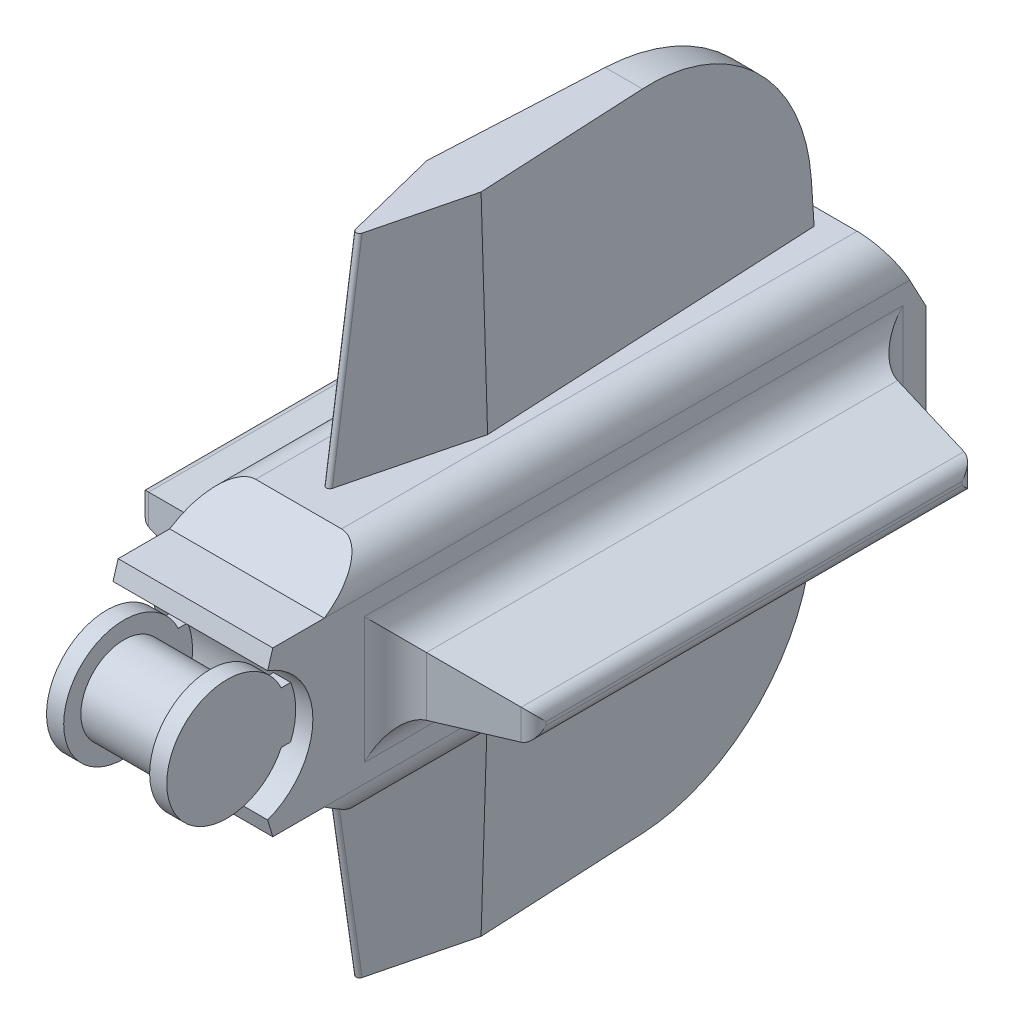
from build123d import *

# Parameters (mm, degrees)
SKETCH1_R                = 3.175
BOSS_EXTRUDE1_DEPTH      = 3.175
SKETCH2_R                = 4.445
BOSS_EXTRUDE2_DEPTH      = 1.27
SKETCH3_W                = 6.35
SKETCH3_H                = 3.81
BOSS_EXTRUDE3_DEPTH      = 1.27
BOSS_EXTRUDE4_DEPTH      = 8.89
BOSS_EXTRUDE4_DEPTH_BACK = 2.54
SKETCH5_R                = 3.175
CUT_EXTRUDE1_DEPTH       = 12.7
FILLET1_R                = 2.54
SKETCH6_W                = 35.56
SKETCH6_H                = 5.08
BOSS_EXTRUDE5_DEPTH      = 8.89
BOSS_EXTRUDE5_TAPER      = 10
FILLET2_R                = 1.016
FILLET3_R                = 2.54
BOSS_EXTRUDE6_DEPTH      = 15.24
BOSS_EXTRUDE6_TAPER      = 2
FILLET4_R                = 0.254
FILLET5_R                = 12.7


with BuildPart() as part:
    # Sketch1 → Boss-Extrude1 (new body, symmetric)
    with BuildSketch(Plane(origin=(0, 0, 0), x_dir=(0, 0, -1), z_dir=(1, 0, 0))):
        Circle(SKETCH1_R)
    extrude(amount=BOSS_EXTRUDE1_DEPTH, both=True)

    # Sketch2 → Boss-Extrude2 (add)
    with BuildSketch(Plane(origin=(3.175, 0, 0), x_dir=(0, 0, -1), z_dir=(1, 0, 0))):
        Circle(SKETCH2_R)
    boss_extrude2 = extrude(amount=BOSS_EXTRUDE2_DEPTH)

    # Mirror1: Boss-Extrude2 across plane
    add(boss_extrude2.mirror(Plane(origin=(0, 0, 0), x_dir=(0, 0, 1), z_dir=(1, 0, 0))))

    # Sketch3 → Boss-Extrude3 (add)
    with BuildSketch(Plane(origin=(4.445, 0, 0), x_dir=(0, 0, -1), z_dir=(1, 0, 0))):
        with Locations((3.175, 0)):
            Rectangle(SKETCH3_W, SKETCH3_H)
    boss_extrude3 = extrude(amount=-BOSS_EXTRUDE3_DEPTH)

    # Mirror2: Boss-Extrude3 across plane
    add(boss_extrude3.mirror(Plane(origin=(0, 0, 0), x_dir=(0, 0, 1), z_dir=(1, 0, 0))))

    # Sketch4 → Boss-Extrude4 (add, two sides)
    with BuildSketch(Plane(origin=(-3.175, 0, 0), x_dir=(0, 0, -1), z_dir=(1, 0, 0))) as boss_extrude4_sk:
        with BuildLine():
            Line((1.737462328, 4.773638514), (2.118462328, 6.043638514))
            Line((2.118462328, 6.043638514), (5.928462328, 6.043638514))
            Line((5.928462328, 6.043638514), (9.738462328, 8.583638514))
            Line((9.738462328, 8.583638514), (47.838462328, 8.583638514))
            Line((47.838462328, 8.583638514), (50.378462328, 3.81))
            Line((50.378462328, 3.81), (50.378462328, -3.81))
            Line((50.378462328, -3.81), (47.838462328, -8.583638514))
            Line((47.838462328, -8.583638514), (9.738462328, -8.583638514))
            Line((9.738462328, -8.583638514), (5.928462328, -6.043638514))
            Line((5.928462328, -6.043638514), (2.118462328, -6.043638514))
            Line((2.118462328, -6.043638514), (1.737462328, -4.773638514))
            ThreePointArc((1.737462328, -4.773638514), (5.08, 0), (1.737462328, 4.773638514))
        make_face()
    extrude(amount=BOSS_EXTRUDE4_DEPTH)
    extrude(boss_extrude4_sk.sketch, amount=-BOSS_EXTRUDE4_DEPTH_BACK)

    # Sketch5 → Cut-Extrude1 (cut)
    with BuildSketch(Plane(origin=(0, 0, -50.378462328), x_dir=(-1, 0, 0), z_dir=(0, 0, -1))):
        Circle(SKETCH5_R)
    extrude(amount=-CUT_EXTRUDE1_DEPTH, mode=Mode.SUBTRACT)

    # Fillet1
    fillet1_edges = [part.edges().sort_by_distance(p)[0] for p in [
        (5.715, -8.583638514, -28.788462328),
        (-5.715, -8.583638514, -28.788462328),
        (-5.715, 8.583638514, -28.788462328),
        (5.715, 8.583638514, -28.788462328),
    ]]
    fillet(fillet1_edges, radius=FILLET1_R)

    # Sketch6 → Boss-Extrude5 (add)
    with BuildSketch(Plane(origin=(5.715, 0, 0), x_dir=(0, 0, -1), z_dir=(1, 0, 0))):
        with Locations((28.788462328, 0)):
            Rectangle(SKETCH6_W, SKETCH6_H)
    boss_extrude5 = extrude(amount=BOSS_EXTRUDE5_DEPTH, taper=BOSS_EXTRUDE5_TAPER)

    # Mirror3: Boss-Extrude5 across plane
    add(boss_extrude5.mirror(Plane(origin=(0, 0, 0), x_dir=(0, 0, 1), z_dir=(1, 0, 0))))

    # Fillet2
    fillet2_edges = [part.edges().sort_by_distance(p)[0] for p in [
        (14.605, 0, -12.576009187),
        (14.605, -0.972453142, -28.788462328),
        (14.605, 0, -45.00091547),
        (14.605, 0.972453142, -28.788462328),
        (-14.605, 0, -12.576009187),
        (-14.605, 0.972453142, -28.788462328),
        (-14.605, 0, -45.00091547),
        (-14.605, -0.972453142, -28.788462328),
    ]]
    fillet(fillet2_edges, radius=FILLET2_R)

    # Fillet3
    fillet3_edges = [part.edges().sort_by_distance(p)[0] for p in [
        (5.715, 0, -11.008462328),
        (5.715, -2.54, -28.788462328),
        (5.715, 0, -46.568462328),
        (5.715, 2.54, -28.788462328),
        (-5.715, 0, -11.008462328),
        (-5.715, -2.54, -28.788462328),
        (-5.715, 0, -46.568462328),
        (-5.715, 2.54, -28.788462328),
    ]]
    fillet(fillet3_edges, radius=FILLET3_R)

    # Sketch7 → Boss-Extrude6 (add)
    with BuildSketch(Plane(origin=(0, 8.583638514, 0), x_dir=(1, 0, 0), z_dir=(0, 1, 0))):
        Polygon((-1.27, 46.568462328), (-2.54, 21.168462328), (0, 11.008462328), (2.54, 21.168462328), (1.27, 46.568462328), align=None)
    boss_extrude6 = extrude(amount=BOSS_EXTRUDE6_DEPTH, taper=BOSS_EXTRUDE6_TAPER)

    # Mirror4: Boss-Extrude6 across plane
    add(boss_extrude6.mirror(Plane.ZX))

    # Fillet4
    fillet4_edges = [part.edges().sort_by_distance(p)[0] for p in [
        (0, 16.203638514, -12.105605329),
        (0, -16.203638514, -12.105605329),
    ]]
    fillet(fillet4_edges, radius=FILLET4_R)

    # Fillet5
    fillet5_edges = [part.edges().sort_by_distance(p)[0] for p in [
        (0, 23.823638514, -46.036269801),
        (0, -23.823638514, -46.036269801),
    ]]
    fillet(fillet5_edges, radius=FILLET5_R)


solid = part.part
